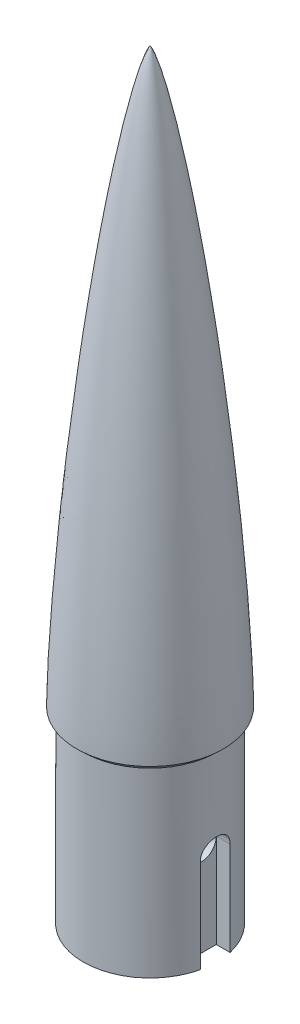
from build123d import *

# Parameters (mm, degrees)
SKETCH1_R               = 8.895
BOSS_EXTRUDE1_DEPTH     = 25
CUT_EXTRUDE1_DEPTH      = 12.5
SKETCH3_R               = 1.984375
CUT_EXTRUDE2_DEPTH      = 9.895
CUT_EXTRUDE2_DEPTH_BACK = 9.895
CHAMFER1_SIZE           = 0.8


with BuildPart() as part:
    # Sketch1 → Boss-Extrude1 (new body)
    with BuildSketch(Plane(origin=(0, 0, 0), x_dir=(1, 0, 0), z_dir=(0, 1, 0))):
        Circle(SKETCH1_R)
    extrude(amount=-BOSS_EXTRUDE1_DEPTH)

    # Sketch2 → Cut-Extrude1 (cut)
    with BuildSketch(Plane.XZ.offset(25)):
        with BuildLine():
            Line((-6.83125, 1.984375), (-6.83125, -1.984375))
            Line((-6.83125, -1.984375), (-8.670829306, -1.984375))
            ThreePointArc((-8.670829306, -1.984375), (-8.895, 0), (-8.670829306, 1.984375))
            Line((-8.670829306, 1.984375), (-6.83125, 1.984375))
        make_face()
    cut_extrude1 = extrude(amount=-CUT_EXTRUDE1_DEPTH, mode=Mode.SUBTRACT)

    # Mirror1: Cut-Extrude1 across plane
    add(cut_extrude1.mirror(Plane(origin=(0, 0, 0), x_dir=(0, 0, 1), z_dir=(1, 0, 0))), mode=Mode.SUBTRACT)

    # Sketch3 → Cut-Extrude2 (cut, two sides)
    with BuildSketch(Plane(origin=(0, 0, 0), x_dir=(0, 0, -1), z_dir=(1, 0, 0))) as cut_extrude2_sk:
        with Locations((0, -12.5)):
            Circle(SKETCH3_R)
    extrude(amount=CUT_EXTRUDE2_DEPTH, mode=Mode.SUBTRACT)
    extrude(cut_extrude2_sk.sketch, amount=-CUT_EXTRUDE2_DEPTH_BACK, mode=Mode.SUBTRACT)

    # Sketch4 → Revolve1 (revolve)
    with BuildSketch(Plane(origin=(0, 0, 0), x_dir=(0, 0, -1), z_dir=(1, 0, 0))):
        with BuildLine():
            Line((9.75, 0), (0, 0))
            Line((0, 0), (0, 76.2))
            add(Edge.make_bspline(
                [(0, 76.2), (0.00748237, 76.196303135), (0.026185272, 76.182931832), (0.048569166, 76.155115052), (0.079016608, 76.11449371), (0.114693992, 76.05782259), (0.160958307, 75.977185044), (0.230182007, 75.841272979), (0.337513198, 75.60317482), (0.508759946, 75.169356672), (0.780720305, 74.373974862), (1.175421329, 73.034171439), (1.784765583, 70.644843338), (2.516344519, 67.293069495), (3.309621674, 63.159543132), (4.115536163, 58.4526801), (4.851127077, 53.734453502), (5.69775641, 47.825772453), (6.460335776, 41.90557874), (7.150044053, 35.976499089), (7.770075125, 30.039829718), (8.224479166, 25.286332313), (8.636093389, 20.528933412), (8.956570125, 16.362955309), (9.199825181, 12.789854007), (9.378943901, 9.810771277), (9.506266384, 7.426602256), (9.610457186, 5.15707962), (9.681192933, 3.242776152), (9.725789572, 1.68405962), (9.742877783, 0.721793084), (9.75, 0.240606643), (9.75, 0)],
                knots=[0, 0, 0, 0, 0, 0.000432339, 0.001198718, 0.001819119, 0.002652992, 0.00389752, 0.006030224, 0.009732147, 0.016211386, 0.028104504, 0.049663776, 0.082235971, 0.144220966, 0.206205912, 0.268191171, 0.33017619, 0.392161358, 0.51613157, 0.578116694, 0.64010179, 0.702086952, 0.764072089, 0.826057153, 0.857049723, 0.888042292, 0.919034838, 0.950027383, 0.975013692, 0.987506846, 1, 1, 1, 1, 1], degree=4))
        make_face()
    revolve(axis=Axis((0, 0, 0), (0, 1, 0)))

    # Chamfer1
    chamfer1_edges = [part.edges().sort_by_distance(p)[0] for p in [
        (-8.895, 0, 0),
    ]]
    chamfer(chamfer1_edges, length=CHAMFER1_SIZE)


solid = part.part
